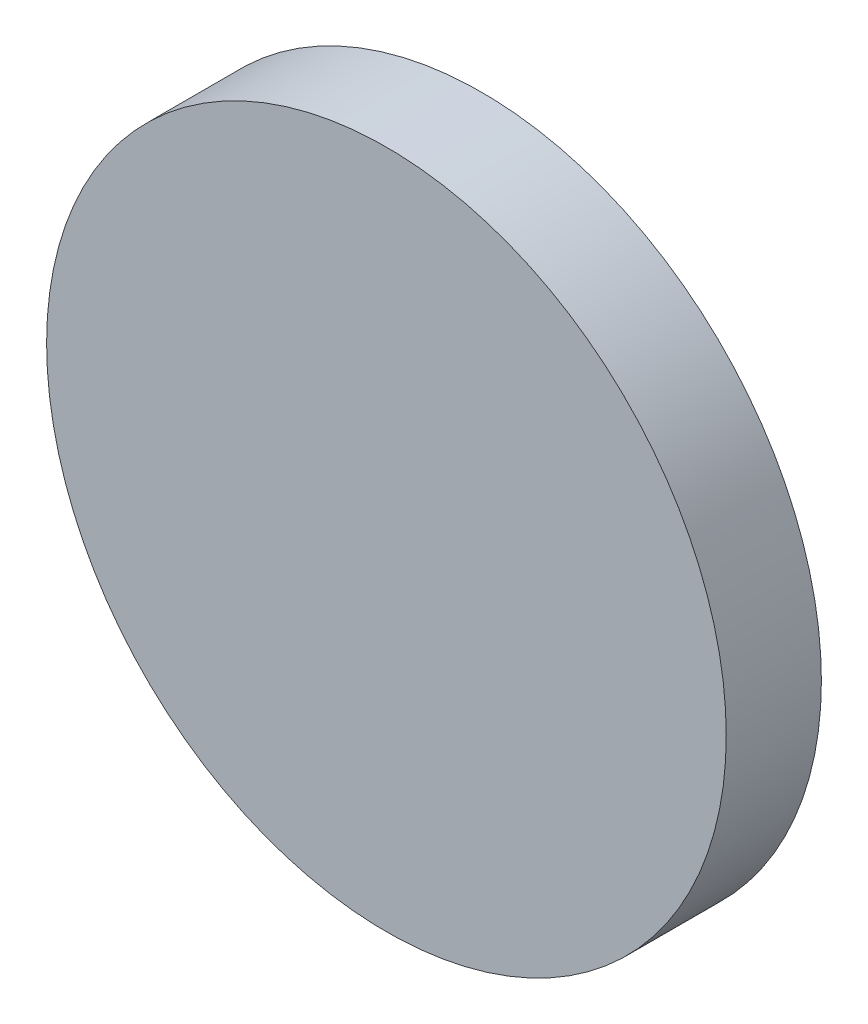
from build123d import *

# Parameters (mm, degrees)
SKETCH1_R           = 12.5
BOSS_EXTRUDE1_DEPTH = 3.5


with BuildPart() as part:
    # Sketch1 → Boss-Extrude1 (new body)
    with BuildSketch(Plane.XY):
        Circle(SKETCH1_R)
    extrude(amount=BOSS_EXTRUDE1_DEPTH)


solid = part.part
